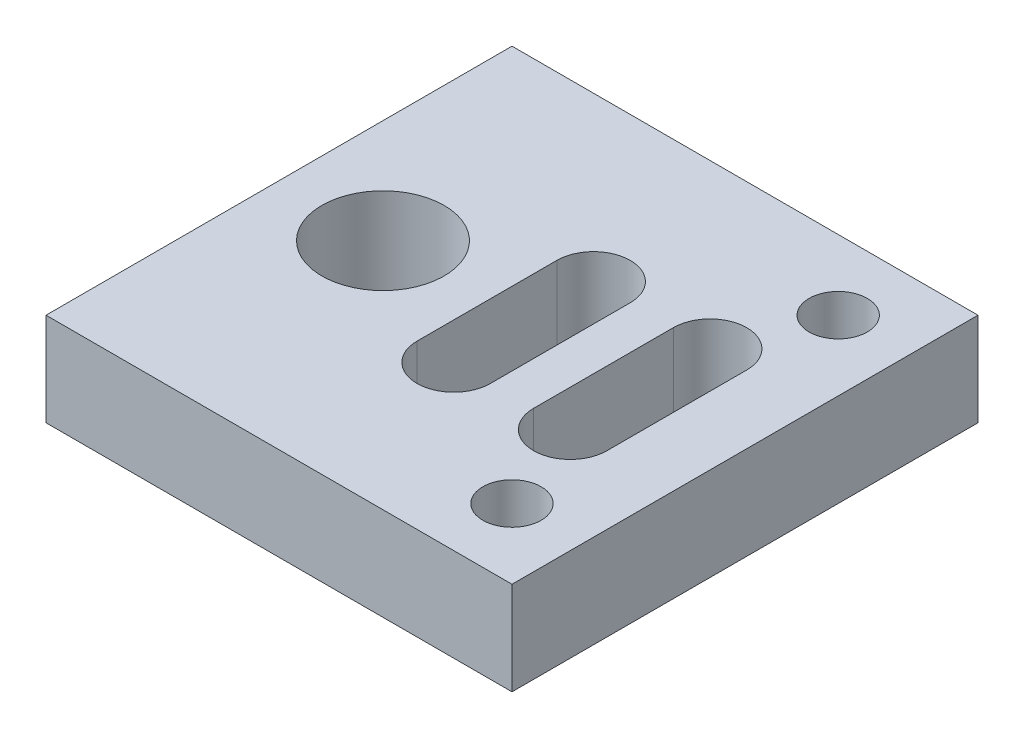
from build123d import *

# Parameters (mm, degrees)
SKETCH1_W           = 20
SKETCH1_H           = 20
SKETCH1_R           = 1.25
SKETCH1_R_2         = 2.625
BOSS_EXTRUDE1_DEPTH = 4


with BuildPart() as part:
    # Sketch1 → Boss-Extrude1 (new body)
    with BuildSketch(Plane(origin=(0, 0, 0), x_dir=(1, 0, 0), z_dir=(0, 1, 0))):
        with Locations((10, 10)):
            Rectangle(SKETCH1_W, SKETCH1_H)
        with Locations((17, 17)):
            Circle(SKETCH1_R, mode=Mode.SUBTRACT)
        with Locations((4.4625, 10)):
            Circle(SKETCH1_R_2, mode=Mode.SUBTRACT)
        with Locations((17, 3)):
            Circle(SKETCH1_R, mode=Mode.SUBTRACT)
        with BuildLine():
            Line((13.925, 7), (13.925, 13))
            ThreePointArc((13.925, 13), (15.5, 14.575), (17.075, 13))
            Line((17.075, 13), (17.075, 7))
            ThreePointArc((17.075, 7), (15.5, 5.425), (13.925, 7))
        make_face(mode=Mode.SUBTRACT)
        with BuildLine():
            Line((8.925, 7), (8.925, 13))
            ThreePointArc((8.925, 13), (10.5, 14.575), (12.075, 13))
            Line((12.075, 13), (12.075, 7))
            ThreePointArc((12.075, 7), (10.5, 5.425), (8.925, 7))
        make_face(mode=Mode.SUBTRACT)
    extrude(amount=-BOSS_EXTRUDE1_DEPTH)


solid = part.part
